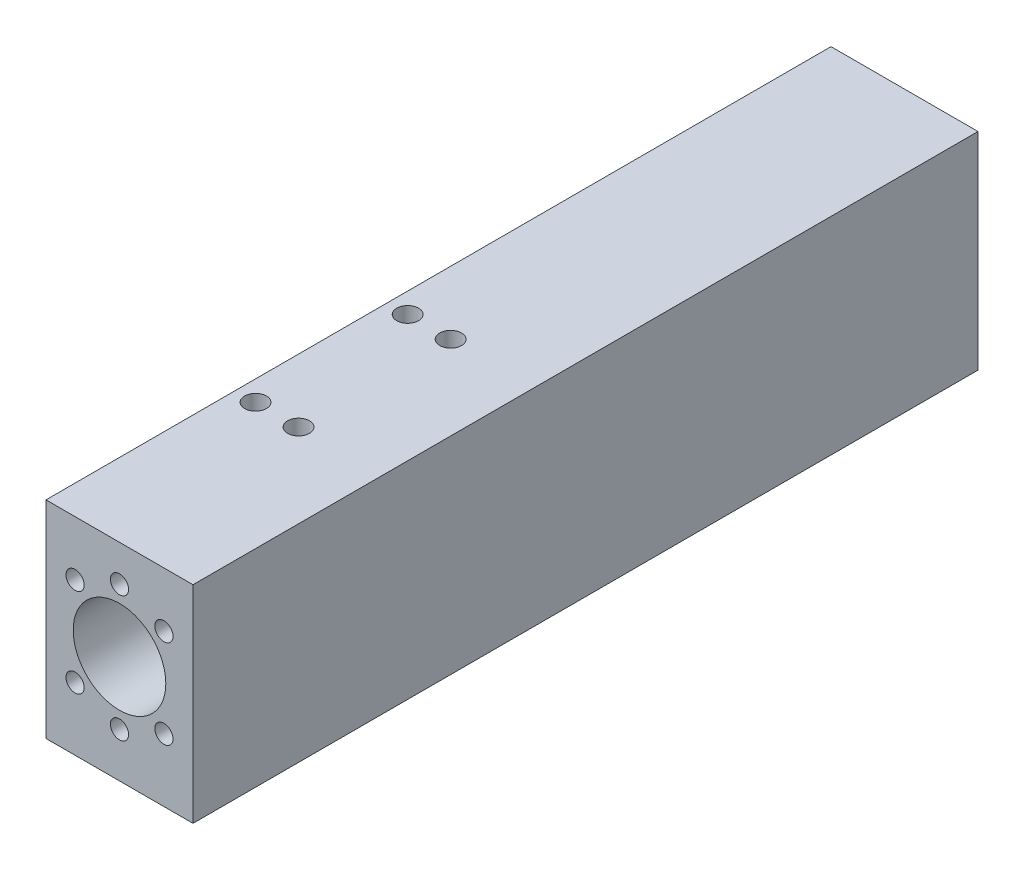
from build123d import *

# Parameters (mm, degrees)
SKETCH1_W           = 44.45
SKETCH1_H           = 62.5
BOSS_EXTRUDE1_DEPTH = 237.38
CUT_EXTRUDE1_DEPTH  = 250.46205503
CUT_EXTRUDE2_DEPTH  = 32
SKETCH2_5_R         = 2.75
CUT_EXTRUDE3_DEPTH  = 12.7
SKETCH4_R           = 3.175
CUT_EXTRUDE4_DEPTH  = 6.35
CUT_EXTRUDE5_DEPTH  = 25.4
SKETCH6_R           = 7.9375
CUT_EXTRUDE6_DEPTH  = 12.7


with BuildPart() as part:
    # Sketch1 → Boss-Extrude1 (new body)
    with BuildSketch(Plane.XY):
        with Locations((22.225, 31.25)):
            Rectangle(SKETCH1_W, SKETCH1_H)
    extrude(amount=BOSS_EXTRUDE1_DEPTH)

    # Sketch2 → Cut-Extrude1 (cut, through all)
    with BuildSketch(Plane.XY.offset(237.38)):
        with BuildLine():
            ThreePointArc((30.225, 32.5), (22.225, 40.5), (14.225, 32.5))
            ThreePointArc((14.225, 32.5), (22.225, 24.5), (30.225, 32.5))
        make_face()
    extrude(amount=-CUT_EXTRUDE1_DEPTH, mode=Mode.SUBTRACT)

    # Sketch2_4 → Cut-Extrude2 (cut)
    with BuildSketch(Plane.XY.offset(237.38)):
        with BuildLine():
            ThreePointArc((36.225, 32.5), (22.225, 46.5), (8.225, 32.5))
            ThreePointArc((8.225, 32.5), (22.225, 18.5), (36.225, 32.5))
        make_face()
        with BuildLine():
            ThreePointArc((30.225, 32.5), (22.225, 24.5), (14.225, 32.5))
            ThreePointArc((14.225, 32.5), (22.225, 40.5), (30.225, 32.5))
        make_face(mode=Mode.SUBTRACT)
    extrude(amount=-CUT_EXTRUDE2_DEPTH, mode=Mode.SUBTRACT)

    # Sketch2_5 → Cut-Extrude3 (cut)
    with BuildSketch(Plane.XY.offset(237.38)):
        with Locations((35.660028843, 45.935028843)):
            Circle(SKETCH2_5_R)
        with Locations((35.660028843, 19.064971157)):
            Circle(SKETCH2_5_R)
        with Locations((22.225, 13.5)):
            Circle(SKETCH2_5_R)
        with Locations((8.789971157, 19.064971157)):
            Circle(SKETCH2_5_R)
        with Locations((8.789971157, 45.935028843)):
            Circle(SKETCH2_5_R)
        with Locations((22.225, 51.5)):
            Circle(SKETCH2_5_R)
    extrude(amount=-CUT_EXTRUDE3_DEPTH, mode=Mode.SUBTRACT)

    # Sketch4 → Cut-Extrude4 (cut)
    with BuildSketch(Plane.ZY):
        with Locations((157.144917681, 35.325)):
            Circle(SKETCH4_R)
        with Locations((157.144917681, 54.375)):
            Circle(SKETCH4_R)
        with BuildLine():
            ThreePointArc((41.4, 55.1), (39.763489429, 54.315991319), (39.348920282, 52.549364905))
            ThreePointArc((39.348920282, 52.549364905), (40.084008681, 51.363489429), (41.4, 50.9))
            ThreePointArc((41.4, 50.9), (43.5, 53), (41.4, 55.1))
        make_face()
        with BuildLine():
            ThreePointArc((13.3, 53), (13.91507576, 51.51507576), (15.4, 50.9))
            ThreePointArc((15.4, 50.9), (17.5, 53), (15.4, 55.1))
            ThreePointArc((15.4, 55.1), (13.91507576, 54.48492424), (13.3, 53))
        make_face()
        with BuildLine():
            ThreePointArc((221.98, 50.9), (224.08, 53), (221.98, 55.1))
            ThreePointArc((221.98, 55.1), (220.343489429, 54.315991319), (219.928920282, 52.549364905))
            ThreePointArc((219.928920282, 52.549364905), (220.664008681, 51.363489429), (221.98, 50.9))
        make_face()
        with BuildLine():
            ThreePointArc((193.88, 53), (194.49507576, 51.51507576), (195.98, 50.9))
            ThreePointArc((195.98, 50.9), (198.08, 53), (195.98, 55.1))
            ThreePointArc((195.98, 55.1), (194.49507576, 54.48492424), (193.88, 53))
        make_face()
        with BuildLine():
            ThreePointArc((219.928920282, 12.450635095), (220.343489429, 10.684008681), (221.98, 9.9))
            ThreePointArc((221.98, 9.9), (224.08, 12), (221.98, 14.1))
            ThreePointArc((221.98, 14.1), (220.664008681, 13.636510571), (219.928920282, 12.450635095))
        make_face()
        with BuildLine():
            ThreePointArc((193.88, 12), (194.49507576, 10.51507576), (195.98, 9.9))
            ThreePointArc((195.98, 9.9), (198.08, 12), (195.98, 14.1))
            ThreePointArc((195.98, 14.1), (194.49507576, 13.48492424), (193.88, 12))
        make_face()
        with BuildLine():
            ThreePointArc((13.3, 12), (13.91507576, 10.51507576), (15.4, 9.9))
            ThreePointArc((15.4, 9.9), (17.5, 12), (15.4, 14.1))
            ThreePointArc((15.4, 14.1), (13.91507576, 13.48492424), (13.3, 12))
        make_face()
        with BuildLine():
            ThreePointArc((39.348920282, 12.450635095), (39.763489429, 10.684008681), (41.4, 9.9))
            ThreePointArc((41.4, 9.9), (43.5, 12), (41.4, 14.1))
            ThreePointArc((41.4, 14.1), (40.084008681, 13.636510571), (39.348920282, 12.450635095))
        make_face()
    extrude(amount=-CUT_EXTRUDE4_DEPTH, mode=Mode.SUBTRACT)

    # Sketch5 → Cut-Extrude5 (cut)
    with BuildSketch(Plane(origin=(0, 62.5, 0), x_dir=(1, 0, 0), z_dir=(0, 1, 0))):
        with BuildLine():
            ThreePointArc((9.425, -134.144917681), (6.125, -130.844917681), (2.825, -134.144917681))
            ThreePointArc((2.825, -134.144917681), (6.125, -137.444917681), (9.425, -134.144917681))
        make_face()
        with BuildLine():
            ThreePointArc((22.425, -134.144917681), (19.125, -130.844917681), (15.825, -134.144917681))
            ThreePointArc((15.825, -134.144917681), (19.125, -137.444917681), (22.425, -134.144917681))
        make_face()
        with BuildLine():
            ThreePointArc((9.425, -180.144917681), (6.125, -176.844917681), (2.825, -180.144917681))
            ThreePointArc((2.825, -180.144917681), (6.125, -183.444917681), (9.425, -180.144917681))
        make_face()
        with BuildLine():
            ThreePointArc((22.425, -180.144917681), (19.125, -176.844917681), (15.825, -180.144917681))
            ThreePointArc((15.825, -180.144917681), (19.125, -183.444917681), (22.425, -180.144917681))
        make_face()
    extrude(amount=-CUT_EXTRUDE5_DEPTH, mode=Mode.SUBTRACT)

    # Sketch6 → Cut-Extrude6 (cut)
    with BuildSketch(Plane.XZ):
        with Locations((22.225, 211.98)):
            Circle(SKETCH6_R)
        with Locations((22.225, 25.4)):
            Circle(SKETCH6_R)
    extrude(amount=-CUT_EXTRUDE6_DEPTH, mode=Mode.SUBTRACT)


solid = part.part
